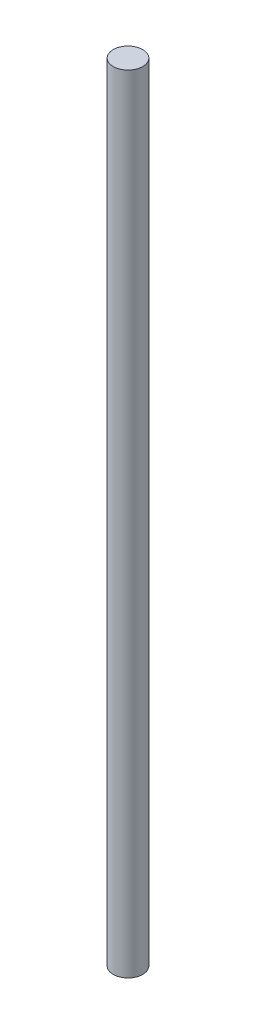
from build123d import *

# Parameters (mm, degrees)
SKETCH1_R           = 4.7625
BOSS_EXTRUDE1_DEPTH = 254


with BuildPart() as part:
    # Sketch1 → Boss-Extrude1 (new body)
    with BuildSketch(Plane(origin=(0, 0, 0), x_dir=(1, 0, 0), z_dir=(0, 1, 0))):
        Circle(SKETCH1_R)
    extrude(amount=BOSS_EXTRUDE1_DEPTH)


solid = part.part
